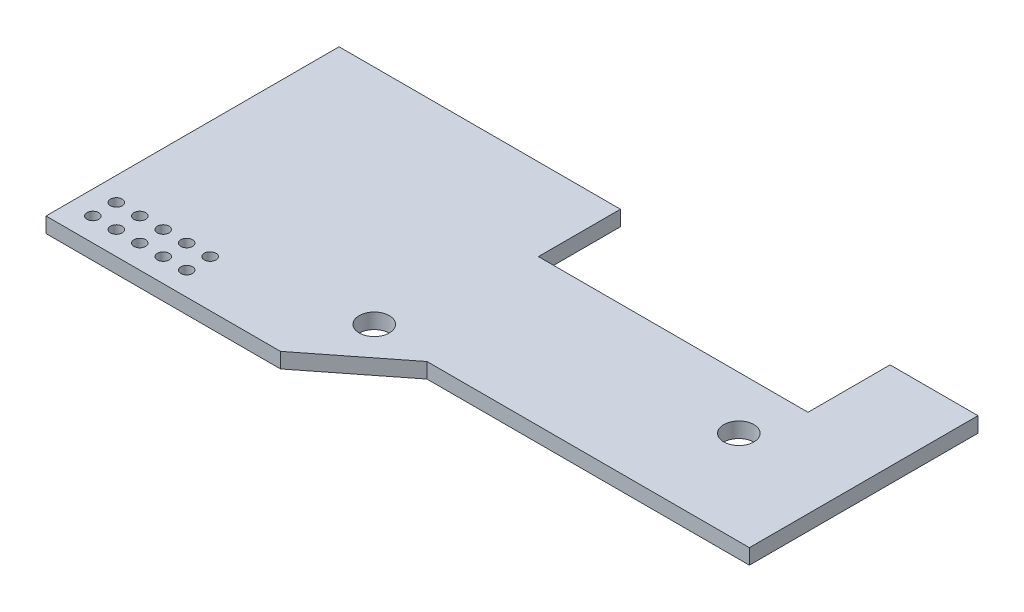
from build123d import *

# Parameters (mm, degrees)
BOSS_EXTRUDE1_DEPTH   = 1.651
SKETCH5_R             = 0.635
CUT_EXTRUDE2_DEPTH    = 2.651
F_4_CLEARANCE_HOLE1_D = 3.2639


with BuildPart() as part:
    # Sketch1 → Boss-Extrude1 (new body)
    with BuildSketch(Plane(origin=(0, 0, 0), x_dir=(1, 0, 0), z_dir=(0, 1, 0))):
        Polygon((0, 0), (30.48, 0), (30.48, -8.89), (45.085, -8.89), (59.69, -8.89), (59.69, 0), (69.215, 0), (69.215, -24.765), (45.085, -24.765), (34.29, -24.765), (25.4, -31.75), (0, -31.75), align=None)
    extrude(amount=BOSS_EXTRUDE1_DEPTH)

    # Sketch5 → Cut-Extrude2 (cut, through all)
    with BuildSketch(Plane(origin=(0, 1.651, 0), x_dir=(1, 0, 0), z_dir=(0, 1, 0))):
        with Locations(Location((2.54, -29.21, 0), (0, 0, 270))):  # turned: the seam where the file's is
            Circle(SKETCH5_R)
        with Locations(Location((5.08, -29.21, 0), (0, 0, 270))):  # turned: the seam where the file's is
            Circle(SKETCH5_R)
        with Locations(Location((7.62, -29.21, 0), (0, 0, 270))):  # turned: the seam where the file's is
            Circle(SKETCH5_R)
        with Locations(Location((10.16, -29.21, 0), (0, 0, 270))):  # turned: the seam where the file's is
            Circle(SKETCH5_R)
        with Locations(Location((12.7, -29.21, 0), (0, 0, 270))):  # turned: the seam where the file's is
            Circle(SKETCH5_R)
        with Locations(Location((2.54, -26.67, 0), (0, 0, 270))):  # turned: the seam where the file's is
            Circle(SKETCH5_R)
        with Locations(Location((5.08, -26.67, 0), (0, 0, 270))):  # turned: the seam where the file's is
            Circle(SKETCH5_R)
        with Locations(Location((7.62, -26.67, 0), (0, 0, 270))):  # turned: the seam where the file's is
            Circle(SKETCH5_R)
        with Locations(Location((10.16, -26.67, 0), (0, 0, 270))):  # turned: the seam where the file's is
            Circle(SKETCH5_R)
        with Locations(Location((12.7, -26.67, 0), (0, 0, 270))):  # turned: the seam where the file's is
            Circle(SKETCH5_R)
    extrude(amount=-CUT_EXTRUDE2_DEPTH, mode=Mode.SUBTRACT)

    # #4 Clearance Hole1 (through all)
    with Locations(Plane(origin=(0, 1.651, 0), x_dir=(-1, 0, 0), z_dir=(0, 1, 0))):
        with Locations((-27.94, 24.13), (-57.912, 14.605)):
            Hole(F_4_CLEARANCE_HOLE1_D / 2)


solid = part.part
